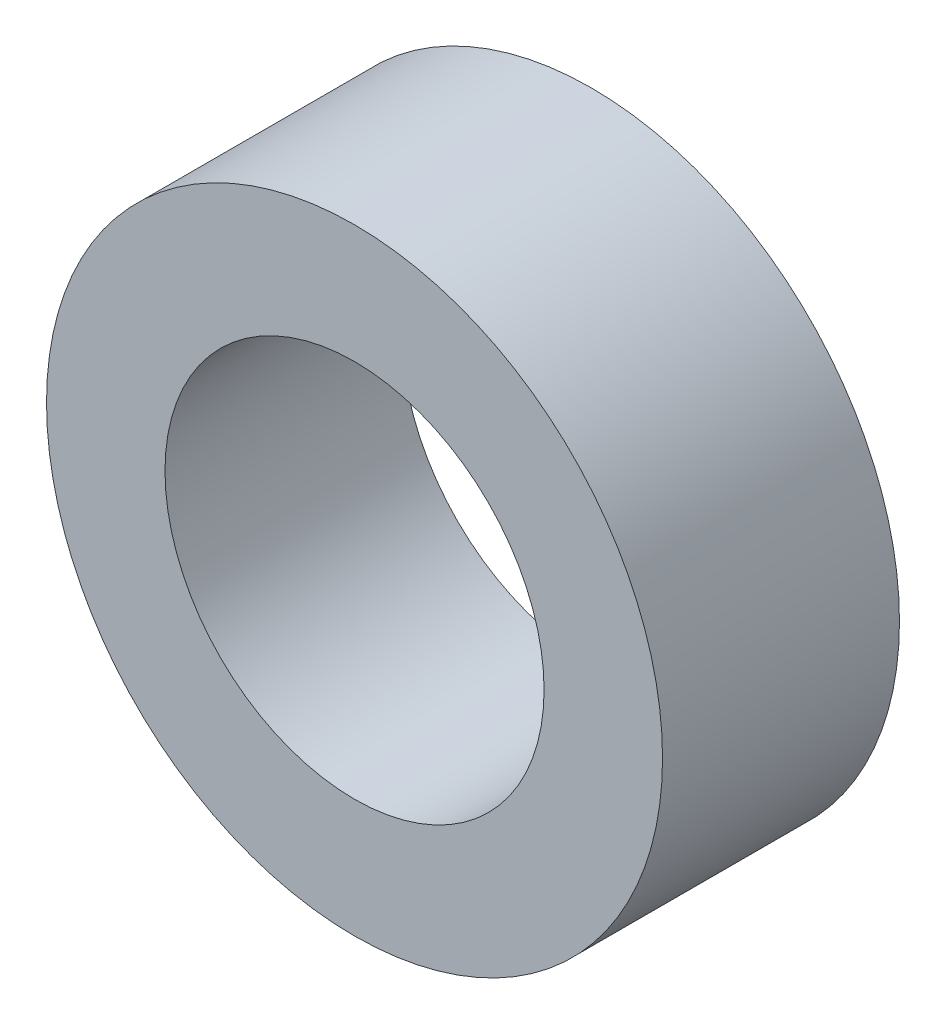
from build123d import *

# Parameters (mm, degrees)
SKETCH_1_R      = 6.5
SKETCH_1_R_2    = 4
EXTRUDE_1_DEPTH = 5


with BuildPart() as part:
    # Эскиз1 → Бобышка-Вытянуть1 (new body)
    with BuildSketch(Plane.XY):
        Circle(SKETCH_1_R)
        Circle(SKETCH_1_R_2, mode=Mode.SUBTRACT)
    extrude(amount=EXTRUDE_1_DEPTH)


solid = part.part
